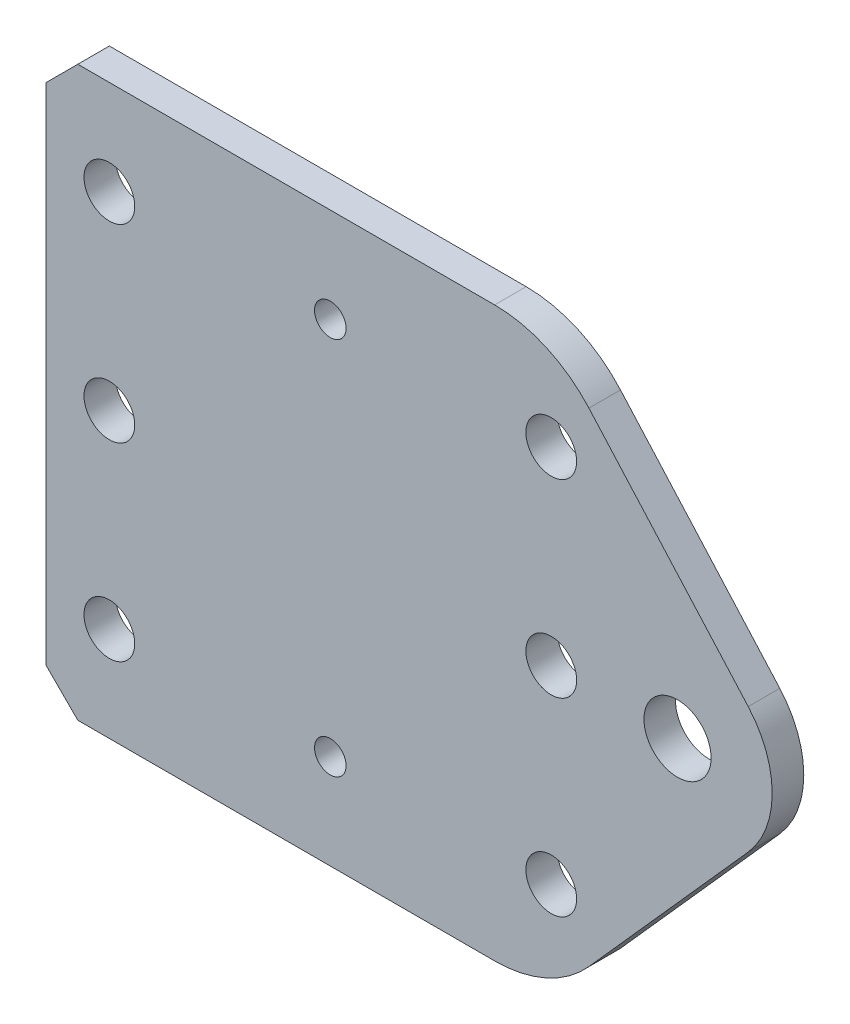
from build123d import *

# Parameters (mm, degrees)
SKETCH1_R              = 3.3782
BOSS_EXTRUDE1_DEPTH    = 3.175
F_10_CLEARANCE_HOLE1_D = 5.1054
CHAMFER1_SIZE          = 3.175
SKETCH4_R              = 1.5875
CUT_EXTRUDE1_DEPTH     = 4.175


with BuildPart() as part:
    # Sketch1 → Boss-Extrude1 (new body)
    with BuildSketch(Plane.XY):
        with BuildLine():
            Line((0, 0), (45.105286642, 0))
            ThreePointArc((45.105286642, 0), (50.301519782, 1.111679969), (54.588060278, 4.252100606))
            Line((54.588060278, 4.252100606), (70.612080227, 22.239075455))
            ThreePointArc((70.612080227, 22.239075455), (73.025, 28.575), (70.612080227, 34.910924545))
            Line((70.612080227, 34.910924545), (54.588060278, 52.897899394))
            ThreePointArc((54.588060278, 52.897899394), (50.301519782, 56.038320031), (45.105286642, 57.15))
            Line((45.105286642, 57.15), (0, 57.15))
            Line((0, 57.15), (0, 0))
        make_face()
        with Locations((63.5, 28.575)):
            Circle(SKETCH1_R, mode=Mode.SUBTRACT)
    extrude(amount=BOSS_EXTRUDE1_DEPTH)

    # #10 Clearance Hole1 (through all)
    with Locations(Plane.XY.offset(3.175)):
        with Locations((50.8, 28.575), (6.35, 28.575), (6.35, 47.625), (50.8, 47.625), (50.8, 9.525), (6.35, 9.525)):
            Hole(F_10_CLEARANCE_HOLE1_D / 2)

    # Chamfer1
    chamfer1_edges = [part.edges().sort_by_distance(p)[0] for p in [
        (0, 57.15, 1.5875),
        (0, 0, 1.5875),
    ]]
    chamfer(chamfer1_edges, length=CHAMFER1_SIZE)

    # Sketch4 → Cut-Extrude1 (cut, through all)
    with BuildSketch(Plane.XY.offset(3.175)):
        with Locations((28.575, 47.625)):
            Circle(SKETCH4_R)
        with Locations((28.575, 9.525)):
            Circle(SKETCH4_R)
    extrude(amount=-CUT_EXTRUDE1_DEPTH, mode=Mode.SUBTRACT)


solid = part.part
